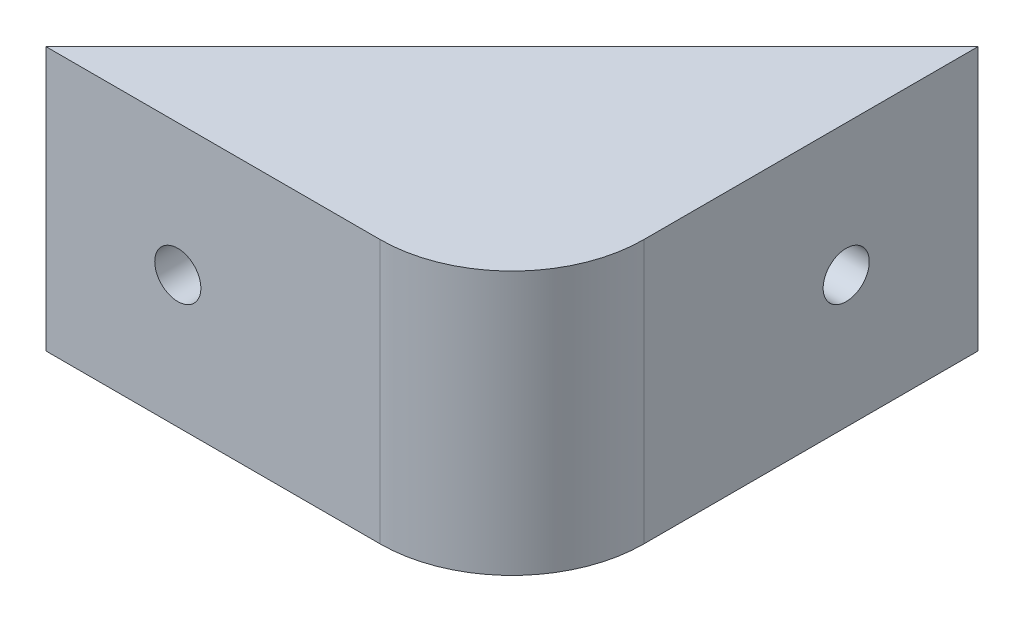
from build123d import *

# Parameters (mm, degrees)
BOSS_EXTRUDE1_DEPTH = 10
FILLET1_R           = 10
CUT_EXTRUDE1_START  = -5
SKETCH5_W           = 25.355339059
SKETCH5_H           = 15
CUT_EXTRUDE1_DEPTH  = 31.355339059
CUT_EXTRUDE3_START  = -5
SKETCH6_W           = 25.355339059
SKETCH6_H           = 15
CUT_EXTRUDE3_DEPTH  = 31.355339059
SKETCH8_W           = 5
SKETCH8_H           = 15
SKETCH9_R           = 1.75
CUT_EXTRUDE4_DEPTH  = 6
SKETCH10_R          = 1.75
CUT_EXTRUDE5_DEPTH  = 6


with BuildPart() as part:
    # Sketch1 → Boss-Extrude1 (new body, symmetric)
    with BuildSketch(Plane(origin=(0, 0, 0), x_dir=(1, 0, 0), z_dir=(0, 1, 0))):
        Polygon((0, 0), (0, 35.355339059), (-35.355339059, 0), align=None)
    extrude(amount=BOSS_EXTRUDE1_DEPTH, both=True)

    # Fillet1
    fillet1_edges = [part.edges().sort_by_distance(p)[0] for p in [
        (0, 0, 0),
    ]]
    fillet(fillet1_edges, radius=FILLET1_R)

    # Sketch5 → Cut-Extrude1 (cut, through all)
    with BuildSketch(Plane.XY.offset(CUT_EXTRUDE1_START)):
        with Locations((-22.67766953, 0)):
            Rectangle(SKETCH5_W, SKETCH5_H)
    extrude(amount=-CUT_EXTRUDE1_DEPTH, mode=Mode.SUBTRACT)

    # Sketch6 → Cut-Extrude3 (cut, through all)
    with BuildSketch(Plane(origin=(0, 0, 0), x_dir=(0, 0, -1), z_dir=(1, 0, 0)).offset(CUT_EXTRUDE3_START)):
        with Locations((22.67766953, 0)):
            Rectangle(SKETCH6_W, SKETCH6_H)
    extrude(amount=-CUT_EXTRUDE3_DEPTH, mode=Mode.SUBTRACT)

    # Sketch8 → Cut-Revolve2 (revolve, cut)
    with BuildSketch(Plane(origin=(0, 0, -10), x_dir=(-1, 0, 0), z_dir=(0, 0, -1))):
        with Locations((7.5, 0)):
            Rectangle(SKETCH8_W, SKETCH8_H)
    revolve(axis=Axis((-10, -7.5, -10), (0, 1, 0)), mode=Mode.SUBTRACT)

    # Sketch9 → Cut-Extrude4 (cut, through all)
    with BuildSketch(Plane.ZY.offset(5)):
        with Locations((-25.355339059, 0)):
            Circle(SKETCH9_R)
    extrude(amount=-CUT_EXTRUDE4_DEPTH, mode=Mode.SUBTRACT)

    # Sketch10 → Cut-Extrude5 (cut, through all)
    with BuildSketch(Plane(origin=(0, 0, -5), x_dir=(-1, 0, 0), z_dir=(0, 0, -1))):
        with Locations((25.355339059, 0)):
            Circle(SKETCH10_R)
    extrude(amount=-CUT_EXTRUDE5_DEPTH, mode=Mode.SUBTRACT)


solid = part.part
